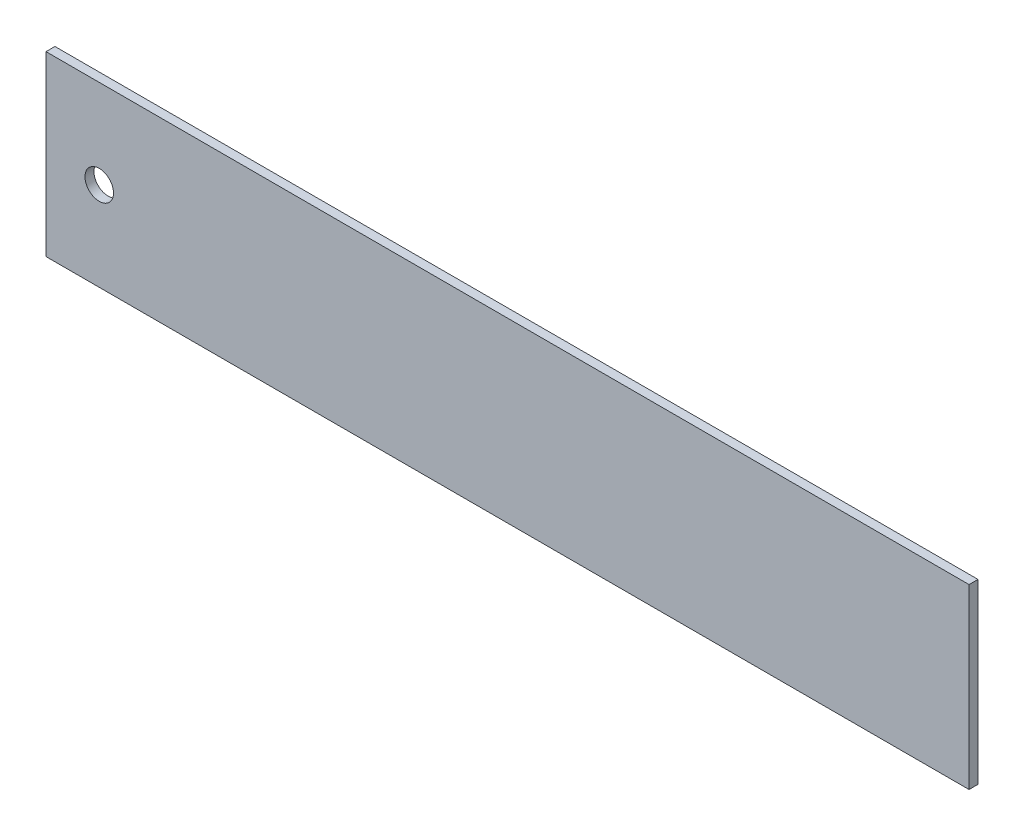
from build123d import *

# Parameters (mm, degrees)
SKETCH1_W           = 165.1
SKETCH1_H           = 31.75
BOSS_EXTRUDE1_DEPTH = 1.6002
SKETCH2_R           = 2.5527
CUT_EXTRUDE1_DEPTH  = 2.54


with BuildPart() as part:
    # Sketch1 → Boss-Extrude1 (new body)
    with BuildSketch(Plane.XY):
        Rectangle(SKETCH1_W, SKETCH1_H)
    extrude(amount=BOSS_EXTRUDE1_DEPTH)

    # Sketch2 → Cut-Extrude1 (cut)
    with BuildSketch(Plane(origin=(0, 0, 0), x_dir=(-1, 0, 0), z_dir=(0, 0, -1))):
        with Locations((73.025, 0)):
            Circle(SKETCH2_R)
    extrude(amount=-CUT_EXTRUDE1_DEPTH, mode=Mode.SUBTRACT)


solid = part.part
